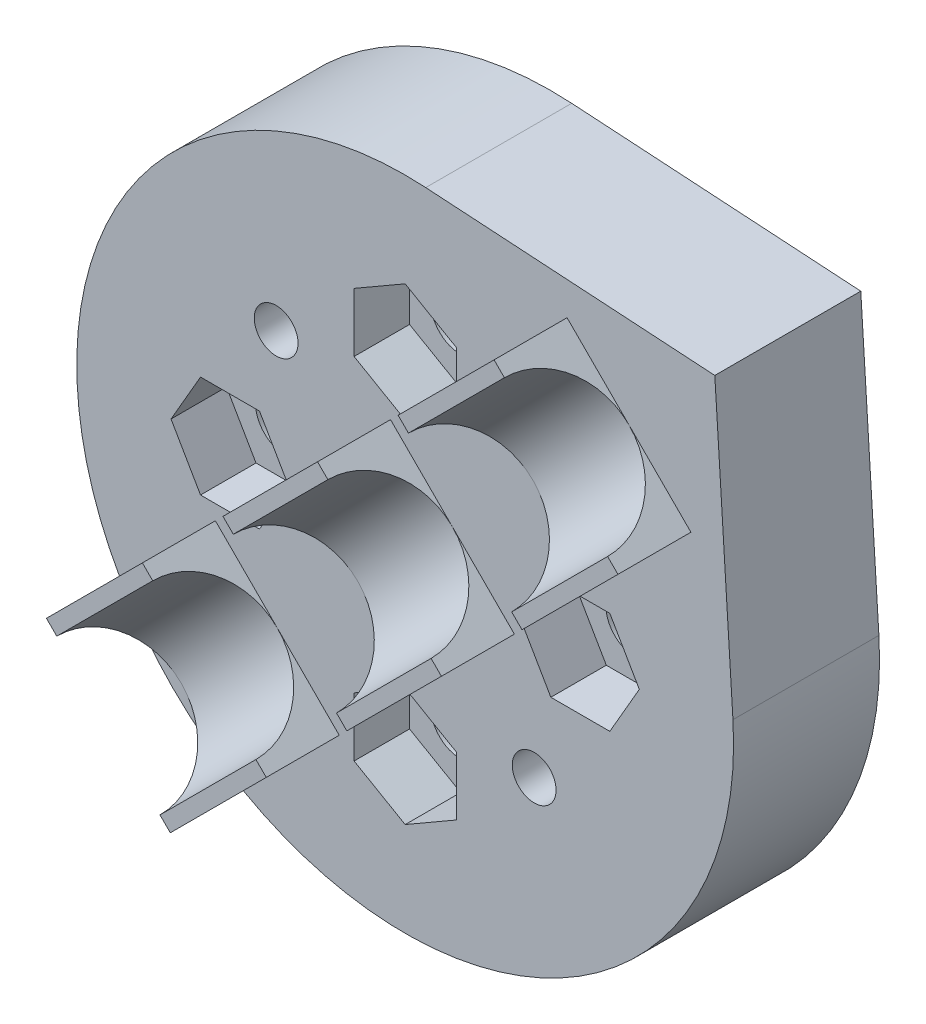
from build123d import *

# Parameters (mm, degrees)
SKETCH1_R               = 16.25
BOSS_EXTRUDE1_DEPTH     = 10
BOSS_EXTRUDE2_START     = 3.1
SKETCH1_3_R             = 16.25
BOSS_EXTRUDE2_DEPTH     = 6.9
BOSS_EXTRUDE3_START     = 3.1
SKETCH1_4_R             = 2.05
BOSS_EXTRUDE3_DEPTH     = 3.1
SKETCH2_R               = 1.5
CUT_EXTRUDE1_DEPTH      = 1
CUT_EXTRUDE1_DEPTH_BACK = 11
BOSS_EXTRUDE4_DEPTH     = 5
SKETCH3_R               = 5
CUT_EXTRUDE2_DEPTH      = 11.134556711
CUT_EXTRUDE2_DEPTH_BACK = 54.505053596


with BuildPart() as part:
    # Sketch1 → Boss-Extrude1 (new body)
    with BuildSketch(Plane(origin=(0, 0, 0), x_dir=(0, 1, 0), z_dir=(0, 0, 1))):
        with BuildLine():
            Line((21.213203436, -21.213203436), (22.455838333, -1.409015532))
            ThreePointArc((22.455838333, -1.409015532), (-15.909902577, 15.909902577), (1.409015532, -22.455838333))
            Line((1.409015532, -22.455838333), (21.213203436, -21.213203436))
        make_face()
        Circle(SKETCH1_R, mode=Mode.SUBTRACT)
    extrude(amount=BOSS_EXTRUDE1_DEPTH)

    # Sketch1_3 → Boss-Extrude2 (add)
    with BuildSketch(Plane(origin=(0, 0, 0), x_dir=(0, 1, 0), z_dir=(0, 0, 1)).offset(BOSS_EXTRUDE2_START)):
        Circle(SKETCH1_3_R)
        Polygon((-3.5, 9.979274058), (0, 7.958548116), (3.5, 9.979274058), (3.5, 14.020725942), (0, 16.041451884), (-3.5, 14.020725942), align=None, mode=Mode.SUBTRACT)
        Polygon((9.979274058, 3.5), (7.958548116, 0), (9.979274058, -3.5), (14.020725942, -3.5), (16.041451884, 0), (14.020725942, 3.5), align=None, mode=Mode.SUBTRACT)
        Polygon((3.5, -9.979274058), (0, -7.958548116), (-3.5, -9.979274058), (-3.5, -14.020725942), (0, -16.041451884), (3.5, -14.020725942), align=None, mode=Mode.SUBTRACT)
        Polygon((-9.979274058, -3.5), (-7.958548116, 0), (-9.979274058, 3.5), (-14.020725942, 3.5), (-16.041451884, 0), (-14.020725942, -3.5), align=None, mode=Mode.SUBTRACT)
    extrude(amount=BOSS_EXTRUDE2_DEPTH)

    # Sketch1_4 → Boss-Extrude3 (add)
    with BuildSketch(Plane(origin=(0, 0, 0), x_dir=(0, 1, 0), z_dir=(0, 0, 1)).offset(BOSS_EXTRUDE3_START)):
        Polygon((3.5, -14.020725942), (3.5, -9.979274058), (0, -7.958548116), (-3.5, -9.979274058), (-3.5, -14.020725942), (0, -16.041451884), align=None)
        with Locations((0, -12)):
            Circle(SKETCH1_4_R, mode=Mode.SUBTRACT)
        Polygon((14.020725942, 3.5), (9.979274058, 3.5), (7.958548116, 0), (9.979274058, -3.5), (14.020725942, -3.5), (16.041451884, 0), align=None)
        with Locations((12, 0)):
            Circle(SKETCH1_4_R, mode=Mode.SUBTRACT)
        Polygon((-3.5, 14.020725942), (-3.5, 9.979274058), (0, 7.958548116), (3.5, 9.979274058), (3.5, 14.020725942), (0, 16.041451884), align=None)
        with Locations((0, 12)):
            Circle(SKETCH1_4_R, mode=Mode.SUBTRACT)
        Polygon((-14.020725942, -3.5), (-9.979274058, -3.5), (-7.958548116, 0), (-9.979274058, 3.5), (-14.020725942, 3.5), (-16.041451884, 0), align=None)
        with Locations((-12, 0)):
            Circle(SKETCH1_4_R, mode=Mode.SUBTRACT)
    extrude(amount=BOSS_EXTRUDE3_DEPTH)

    # Sketch2 → Cut-Extrude1 (cut, two sides)
    with BuildSketch(Plane.XY.offset(10)) as cut_extrude1_sk:
        with Locations((8.838834765, -8.838834765)):
            Circle(SKETCH2_R)
        with Locations((-8.838834765, 8.838834765)):
            Circle(SKETCH2_R)
    extrude(amount=CUT_EXTRUDE1_DEPTH, mode=Mode.SUBTRACT)
    extrude(cut_extrude1_sk.sketch, amount=-CUT_EXTRUDE1_DEPTH_BACK, mode=Mode.SUBTRACT)

    # Sketch2_3 → Boss-Extrude4 (add)
    with BuildSketch(Plane.XY.offset(10)):
        Polygon((-5.224829065, -12.295896877), (-12.295896877, -5.224829065), (-18.869320131, -11.798252319), (-11.798252319, -18.869320131), align=None)
        Polygon((-12.295896877, -5.224829065), (-13.003003658, -4.517722284), (-19.576426912, -11.091145538), (-18.869320131, -11.798252319), align=None)
        Polygon((-4.517722284, -13.003003658), (-5.224829065, -12.295896877), (-11.798252319, -18.869320131), (-11.091145538, -19.576426912), align=None)
        Polygon((6.775170935, -0.295896877), (-0.295896877, 6.775170935), (-6.775170935, 0.295896877), (0.295896877, -6.775170935), align=None)
        Polygon((-0.295896877, 6.775170935), (-1.003003658, 7.482277716), (-7.482277716, 1.003003658), (-6.775170935, 0.295896877), align=None)
        Polygon((7.482277716, -1.003003658), (6.775170935, -0.295896877), (0.295896877, -6.775170935), (1.003003658, -7.482277716), align=None)
        Polygon((19.576426912, 11.091145538), (18.869320131, 11.798252319), (12.295896877, 5.224829065), (13.003003658, 4.517722284), align=None)
        Polygon((18.869320131, 11.798252319), (11.798252319, 18.869320131), (5.224829065, 12.295896877), (12.295896877, 5.224829065), align=None)
        Polygon((11.798252319, 18.869320131), (11.091145538, 19.576426912), (4.517722284, 13.003003658), (5.224829065, 12.295896877), align=None)
    extrude(amount=BOSS_EXTRUDE4_DEPTH)

    # Sketch3 → Cut-Extrude2 (cut, two sides)
    with BuildSketch(Plane(origin=(-15.333786225, -15.333786225, 0), x_dir=(0.707106781, -0.707106781, 0), z_dir=(-0.707106781, -0.707106781, 0))) as cut_extrude2_sk:
        with Locations((0, 15)):
            Circle(SKETCH3_R)
    extrude(amount=CUT_EXTRUDE2_DEPTH, mode=Mode.SUBTRACT)
    extrude(cut_extrude2_sk.sketch, amount=-CUT_EXTRUDE2_DEPTH_BACK, mode=Mode.SUBTRACT)


solid = part.part
